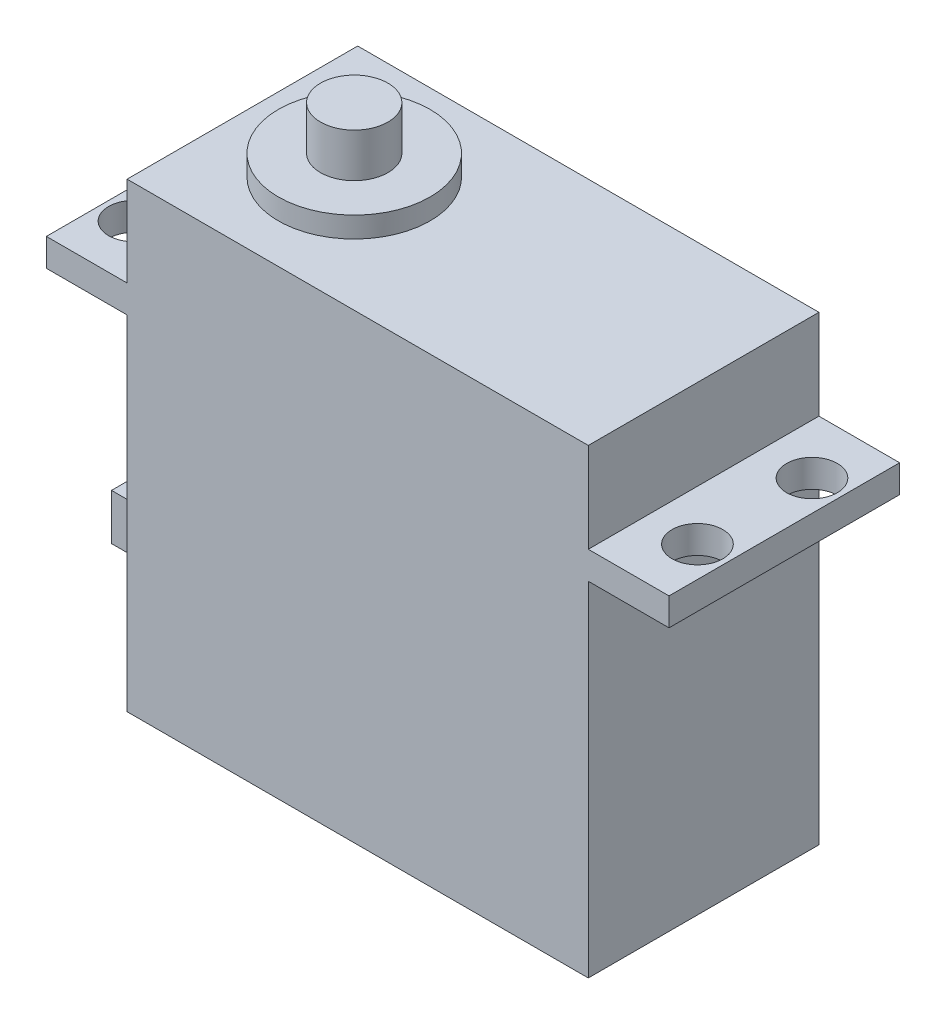
from build123d import *

# Parameters (mm, degrees)
SKETCH_1_W              = 40
SKETCH_1_H              = 40
EXTRUDE_1_DEPTH         = 20
SKETCH_2_R              = 6.58
EXTRUDE_2_DEPTH         = 1.8
SKETCH_3_R              = 2.925
EXTRUDE_3_DEPTH         = 3.8
SKETCH_4_W              = 7
SKETCH_4_H              = 20
EXTRUDE_4_DEPTH         = 2.4
HOLE_WIZARD_4_4_4_4_1_D = 4.4
SKETCH_7_W              = 5.7
SKETCH_7_H              = 4
EXTRUDE_5_DEPTH         = 8.5


with BuildPart() as part:
    # 草图1 → 凸台-拉伸1 (new body)
    with BuildSketch(Plane.XY):
        Rectangle(SKETCH_1_W, SKETCH_1_H)
    extrude(amount=EXTRUDE_1_DEPTH)

    # 草图2 → 凸台-拉伸2 (add)
    with BuildSketch(Plane(origin=(0, 20, 0), x_dir=(1, 0, 0), z_dir=(0, 1, 0))):
        with Locations((-10.3, -10)):
            Circle(SKETCH_2_R)
    extrude(amount=EXTRUDE_2_DEPTH)

    # 草图3 → 凸台-拉伸3 (add)
    with BuildSketch(Plane(origin=(0, 21.8, 0), x_dir=(1, 0, 0), z_dir=(0, 1, 0))):
        with Locations((-10.3, -10)):
            Circle(SKETCH_3_R)
    extrude(amount=EXTRUDE_3_DEPTH)

    # 草图4 → 凸台-拉伸4 (add)
    with BuildSketch(Plane(origin=(0, 12.2, 0), x_dir=(1, 0, 0), z_dir=(0, 1, 0))):
        with Locations((-23.5, -10)):
            Rectangle(SKETCH_4_W, SKETCH_4_H)
        with Locations((23.5, -10)):
            Rectangle(SKETCH_4_W, SKETCH_4_H)
    extrude(amount=-EXTRUDE_4_DEPTH)

    # Ø4.4 (4.4) 直径孔1 (through all)
    with Locations(Plane(origin=(0, 12.2, 0), x_dir=(1, 0, 0), z_dir=(0, 1, 0))):
        with Locations((-24.35, -4.95), (-24.35, -15.05), (24.35, -4.95), (24.35, -14.883974449)):
            Hole(HOLE_WIZARD_4_4_4_4_1_D / 2)

    # 草图7 → 凸台-拉伸5 (add)
    with BuildSketch(Plane.ZY.offset(20)):
        with Locations((10, -13.2)):
            Rectangle(SKETCH_7_W, SKETCH_7_H)
    extrude(amount=EXTRUDE_5_DEPTH)


solid = part.part
